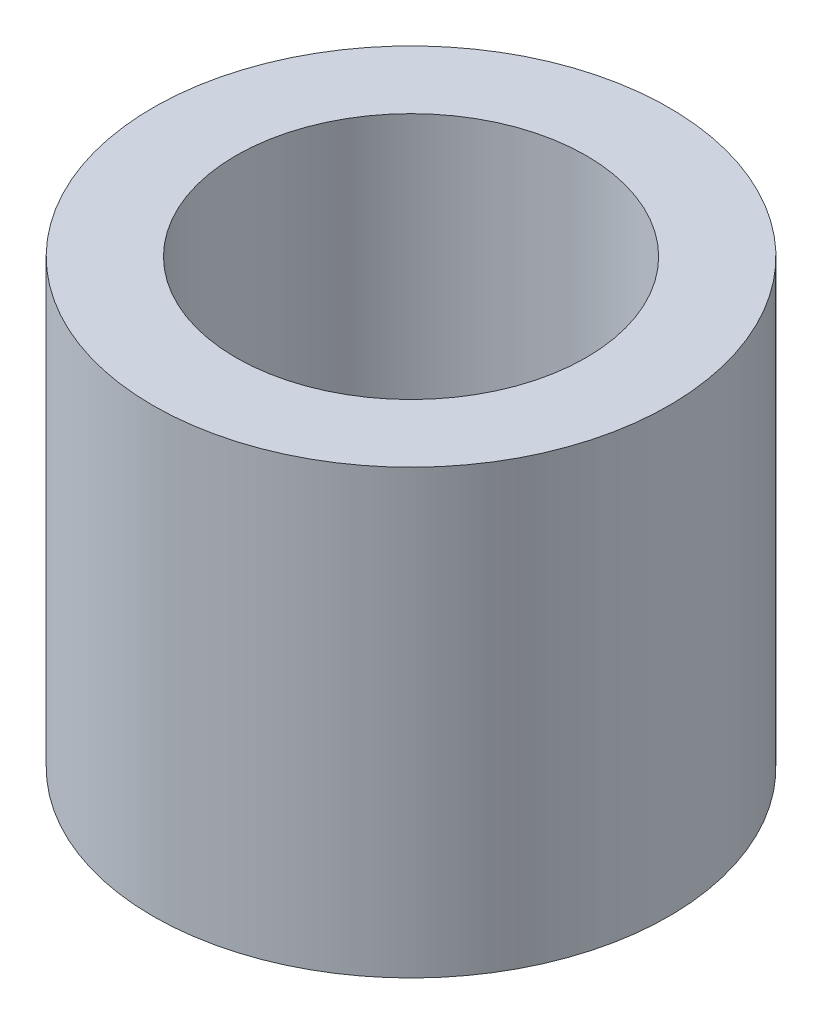
from build123d import *

# Parameters (mm, degrees)
SKETCH1_R           = 44.45
SKETCH1_R_2         = 30.1625
BOSS_EXTRUDE1_DEPTH = 76.2


with BuildPart() as part:
    # Sketch1 → Boss-Extrude1 (new body)
    with BuildSketch(Plane(origin=(0, 0, 0), x_dir=(1, 0, 0), z_dir=(0, 1, 0))):
        Circle(SKETCH1_R)
        Circle(SKETCH1_R_2, mode=Mode.SUBTRACT)
    extrude(amount=BOSS_EXTRUDE1_DEPTH)


solid = part.part
